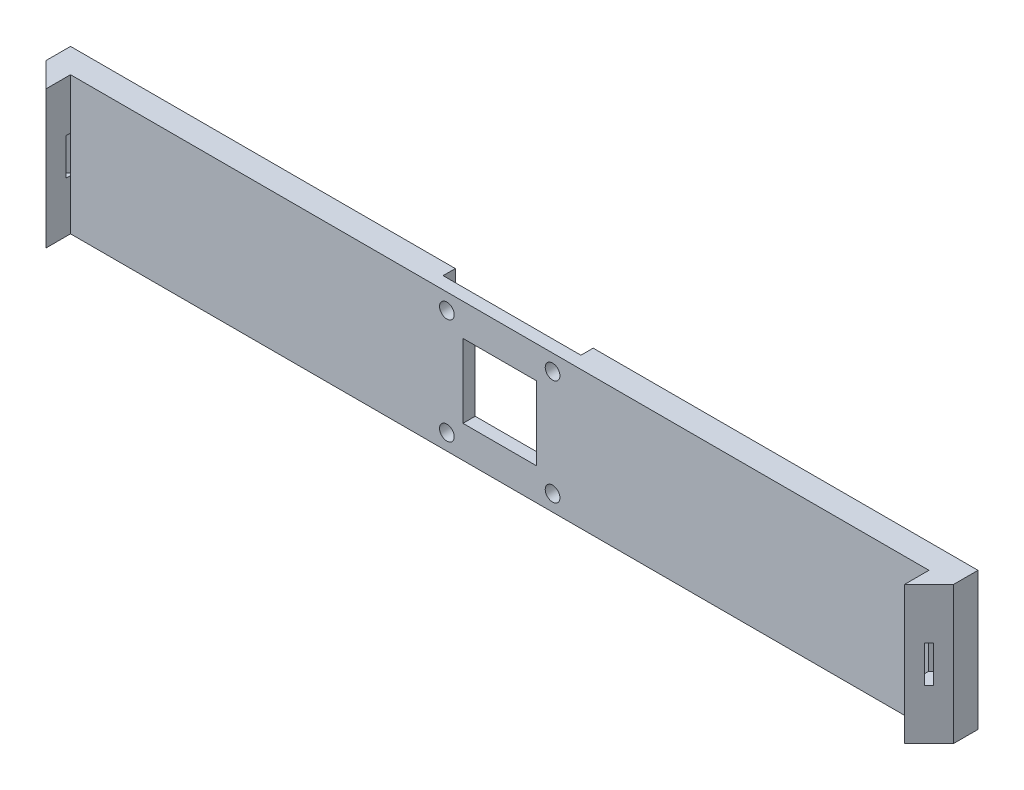
from build123d import *

# Parameters (mm, degrees)
SKETCH1_W           = 350
SKETCH1_H           = 56.2
BOSS_EXTRUDE1_DEPTH = 10
SKETCH2_W           = 56.2
SKETCH2_H           = 56.2
CUT_EXTRUDE1_DEPTH  = 5
SKETCH3_W           = 10
SKETCH3_H           = 56.2
BOSS_EXTRUDE2_DEPTH = 10
SKETCH4_W           = 10
SKETCH4_H           = 56.2
BOSS_EXTRUDE3_DEPTH = 10
CUT_EXTRUDE2_DEPTH  = 56.2
SKETCH6_W           = 10
SKETCH6_H           = 56.2
BOSS_EXTRUDE4_DEPTH = 10
SKETCH7_W           = 10
SKETCH7_H           = 56.2
BOSS_EXTRUDE5_DEPTH = 10
CUT_EXTRUDE3_DEPTH  = 56.2
SKETCH9_W           = 30
SKETCH9_H           = 30
CUT_EXTRUDE4_DEPTH  = 5
SKETCH10_R          = 3
CUT_EXTRUDE5_DEPTH  = 5
SKETCH11_W          = 2.5
SKETCH11_H          = 15
CUT_EXTRUDE6_DEPTH  = 7
SKETCH12_W          = 2.5
SKETCH12_H          = 15
CUT_EXTRUDE8_DEPTH  = 7
SKETCH14_W          = 56.2
SKETCH14_H          = 56.2
SKETCH14_R          = 3
SKETCH14_W_2        = 30
SKETCH14_H_2        = 30
BOSS_EXTRUDE7_DEPTH = 5
SKETCH15_W          = 56.2
SKETCH15_H          = 56.2
CUT_EXTRUDE9_DEPTH  = 5


with BuildPart() as part:
    # Sketch1 → Boss-Extrude1 (new body)
    with BuildSketch(Plane.XY):
        Rectangle(SKETCH1_W, SKETCH1_H)
    extrude(amount=BOSS_EXTRUDE1_DEPTH)

    # Sketch2 → Cut-Extrude1 (cut)
    with BuildSketch(Plane.XY.offset(10)):
        Rectangle(SKETCH2_W, SKETCH2_H)
    extrude(amount=-CUT_EXTRUDE1_DEPTH, mode=Mode.SUBTRACT)

    # Sketch3 → Boss-Extrude2 (add)
    with BuildSketch(Plane(origin=(175, 0, 0), x_dir=(0, 0, -1), z_dir=(1, 0, 0))):
        with Locations((-5, 0)):
            Rectangle(SKETCH3_W, SKETCH3_H)
    extrude(amount=BOSS_EXTRUDE2_DEPTH)

    # Sketch4 → Boss-Extrude3 (add)
    with BuildSketch(Plane.XY.offset(10)):
        with Locations((180, 0)):
            Rectangle(SKETCH4_W, SKETCH4_H)
    extrude(amount=BOSS_EXTRUDE3_DEPTH)

    # Sketch5 → Cut-Extrude2 (cut)
    with BuildSketch(Plane(origin=(0, 28.1, 0), x_dir=(1, 0, 0), z_dir=(0, 1, 0))):
        Polygon((175, -20), (185, -10), (185, -20), align=None)
    extrude(amount=-CUT_EXTRUDE2_DEPTH, mode=Mode.SUBTRACT)

    # Sketch6 → Boss-Extrude4 (add)
    with BuildSketch(Plane.ZY.offset(175)):
        with Locations((5, 0)):
            Rectangle(SKETCH6_W, SKETCH6_H)
    extrude(amount=BOSS_EXTRUDE4_DEPTH)

    # Sketch7 → Boss-Extrude5 (add)
    with BuildSketch(Plane.XY.offset(10)):
        with Locations((-180, 0)):
            Rectangle(SKETCH7_W, SKETCH7_H)
    extrude(amount=BOSS_EXTRUDE5_DEPTH)

    # Sketch8 → Cut-Extrude3 (cut)
    with BuildSketch(Plane(origin=(0, 28.1, 0), x_dir=(1, 0, 0), z_dir=(0, 1, 0))):
        Polygon((-175, -20), (-185, -10), (-185, -20), align=None)
    extrude(amount=-CUT_EXTRUDE3_DEPTH, mode=Mode.SUBTRACT)

    # Sketch9 → Cut-Extrude4 (cut)
    with BuildSketch(Plane.XY.offset(5)):
        Rectangle(SKETCH9_W, SKETCH9_H)
    extrude(amount=-CUT_EXTRUDE4_DEPTH, mode=Mode.SUBTRACT)

    # Sketch10 → Cut-Extrude5 (cut)
    with BuildSketch(Plane.XY.offset(5)):
        with Locations((21.55, 21.55)):
            Circle(SKETCH10_R)
        with Locations((-21.55, -21.55)):
            Circle(SKETCH10_R)
        with Locations((-21.55, 21.55)):
            Circle(SKETCH10_R)
        with Locations((21.55, -21.55)):
            Circle(SKETCH10_R)
    extrude(amount=-CUT_EXTRUDE5_DEPTH, mode=Mode.SUBTRACT)

    # Sketch11 → Cut-Extrude6 (cut)
    with BuildSketch(Plane(origin=(97.5, 0, 97.5), x_dir=(0.707106781, 0, -0.707106781), z_dir=(0.707106781, 0, 0.707106781))):
        with Locations((116.672618896, 0)):
            Rectangle(SKETCH11_W, SKETCH11_H)
    extrude(amount=-CUT_EXTRUDE6_DEPTH, mode=Mode.SUBTRACT)

    # Sketch12 → Cut-Extrude8 (cut)
    with BuildSketch(Plane(origin=(-97.5, 0, 97.5), x_dir=(0.707106781, 0, 0.707106781), z_dir=(-0.707106781, 0, 0.707106781))):
        with Locations((-116.672618896, 0)):
            Rectangle(SKETCH12_W, SKETCH12_H)
    extrude(amount=-CUT_EXTRUDE8_DEPTH, mode=Mode.SUBTRACT)

    # Sketch14 → Boss-Extrude7 (add)
    with BuildSketch(Plane.XY.offset(5)):
        Rectangle(SKETCH14_W, SKETCH14_H)
        with Locations((-21.55, 21.55)):
            Circle(SKETCH14_R, mode=Mode.SUBTRACT)
        with Locations((21.55, 21.55)):
            Circle(SKETCH14_R, mode=Mode.SUBTRACT)
        with Locations((21.55, -21.55)):
            Circle(SKETCH14_R, mode=Mode.SUBTRACT)
        with Locations((-21.55, -21.55)):
            Circle(SKETCH14_R, mode=Mode.SUBTRACT)
        Rectangle(SKETCH14_W_2, SKETCH14_H_2, mode=Mode.SUBTRACT)
    extrude(amount=BOSS_EXTRUDE7_DEPTH)

    # Sketch15 → Cut-Extrude9 (cut)
    with BuildSketch(Plane(origin=(0, 0, 0), x_dir=(-1, 0, 0), z_dir=(0, 0, -1))):
        Rectangle(SKETCH15_W, SKETCH15_H)
    extrude(amount=-CUT_EXTRUDE9_DEPTH, mode=Mode.SUBTRACT)


solid = part.part
